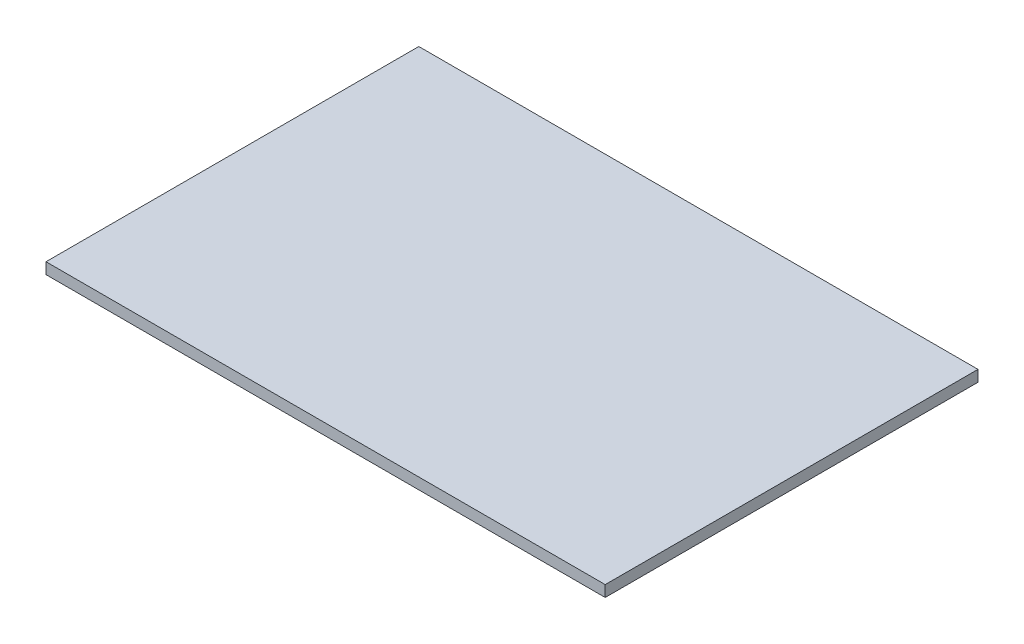
from build123d import *

# Parameters (mm, degrees)
SKETCH1_W           = 150
SKETCH1_H           = 100
BOSS_EXTRUDE1_DEPTH = 3


with BuildPart() as part:
    # Sketch1 → Boss-Extrude1 (new body)
    with BuildSketch(Plane(origin=(0, 0, 0), x_dir=(1, 0, 0), z_dir=(0, 1, 0))):
        with Locations((75, 50)):
            Rectangle(SKETCH1_W, SKETCH1_H)
    extrude(amount=BOSS_EXTRUDE1_DEPTH)


solid = part.part
